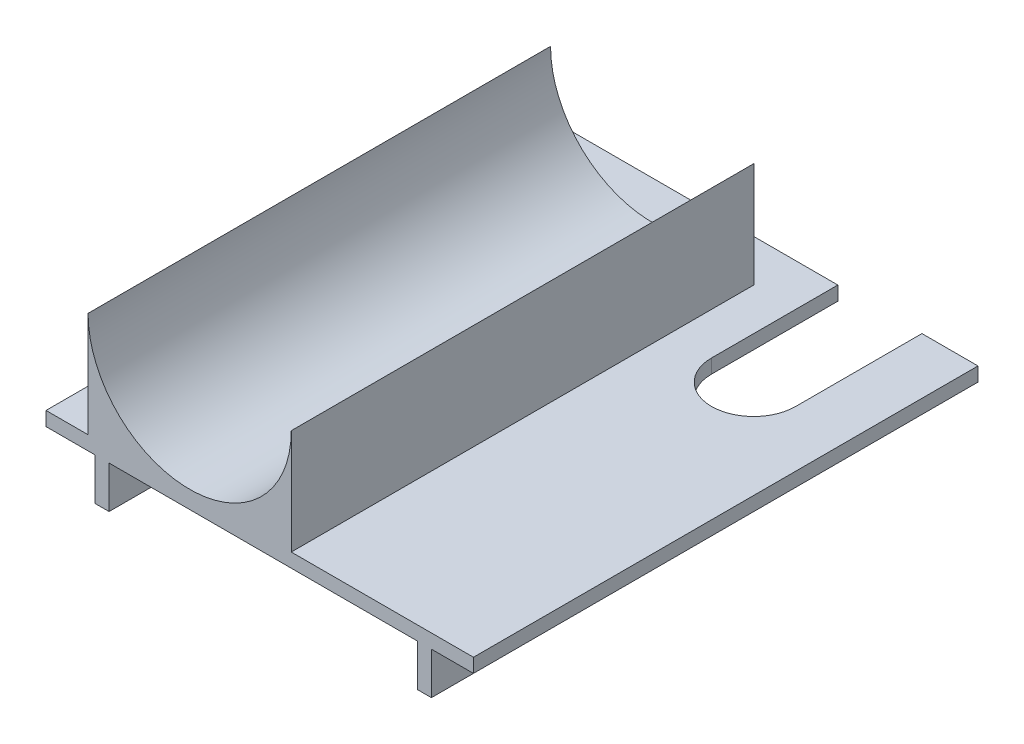
from build123d import *

# Parameters (mm, degrees)
BOSS_EXTRUDE1_DEPTH = 360
CUT_EXTRUDE1_DEPTH  = 360
SKETCH4_W           = 30
SKETCH4_H           = 75
CUT_EXTRUDE2_DEPTH  = 276


with BuildPart() as part:
    # Sketch1 → Boss-Extrude1 (new body)
    with BuildSketch(Plane.XY):
        with BuildLine():
            Line((-72.5, 2.5), (-102.5, 2.5))
            Line((-102.5, 2.5), (-102.5, -7.5))
            Line((-102.5, -7.5), (-67.5, -7.5))
            Line((-67.5, -7.5), (-67.5, -37.5))
            Line((-67.5, -37.5), (-57.5, -37.5))
            Line((-57.5, -37.5), (-57.5, -7.5))
            Line((-57.5, -7.5), (57.5, -7.5))
            Line((57.5, -7.5), (67.5, -7.5))
            Line((67.5, -7.5), (162.5, -7.5))
            Line((162.5, -7.5), (162.5, -37.5))
            Line((162.5, -37.5), (172.5, -37.5))
            Line((172.5, -37.5), (172.5, -7.5))
            Line((172.5, -7.5), (202.5, -7.5))
            Line((202.5, -7.5), (202.5, 2.5))
            Line((202.5, 2.5), (72.5, 2.5))
            Line((72.5, 2.5), (72.5, 77.5))
            ThreePointArc((72.5, 77.5), (0, 5), (-72.5, 77.5))
            Line((-72.5, 77.5), (-72.5, 2.5))
        make_face()
    extrude(amount=-BOSS_EXTRUDE1_DEPTH)

    # Sketch3 → Cut-Extrude1 (cut)
    with BuildSketch(Plane(origin=(0, 2.5, 0), x_dir=(1, 0, 0), z_dir=(0, 1, 0))):
        with BuildLine():
            Line((102.5, 360), (102.5, 270))
            ThreePointArc((102.5, 270), (132.5, 239.895652489), (162.5, 270))
            Line((162.5, 270), (162.5, 360))
            Line((162.5, 360), (102.5, 360))
        make_face()
    extrude(amount=-CUT_EXTRUDE1_DEPTH, mode=Mode.SUBTRACT)

    # Sketch4 → Cut-Extrude2 (cut, through all)
    with BuildSketch(Plane.ZY.offset(72.5)):
        with Locations((-345, 40)):
            Rectangle(SKETCH4_W, SKETCH4_H)
    extrude(amount=-CUT_EXTRUDE2_DEPTH, mode=Mode.SUBTRACT)


solid = part.part
